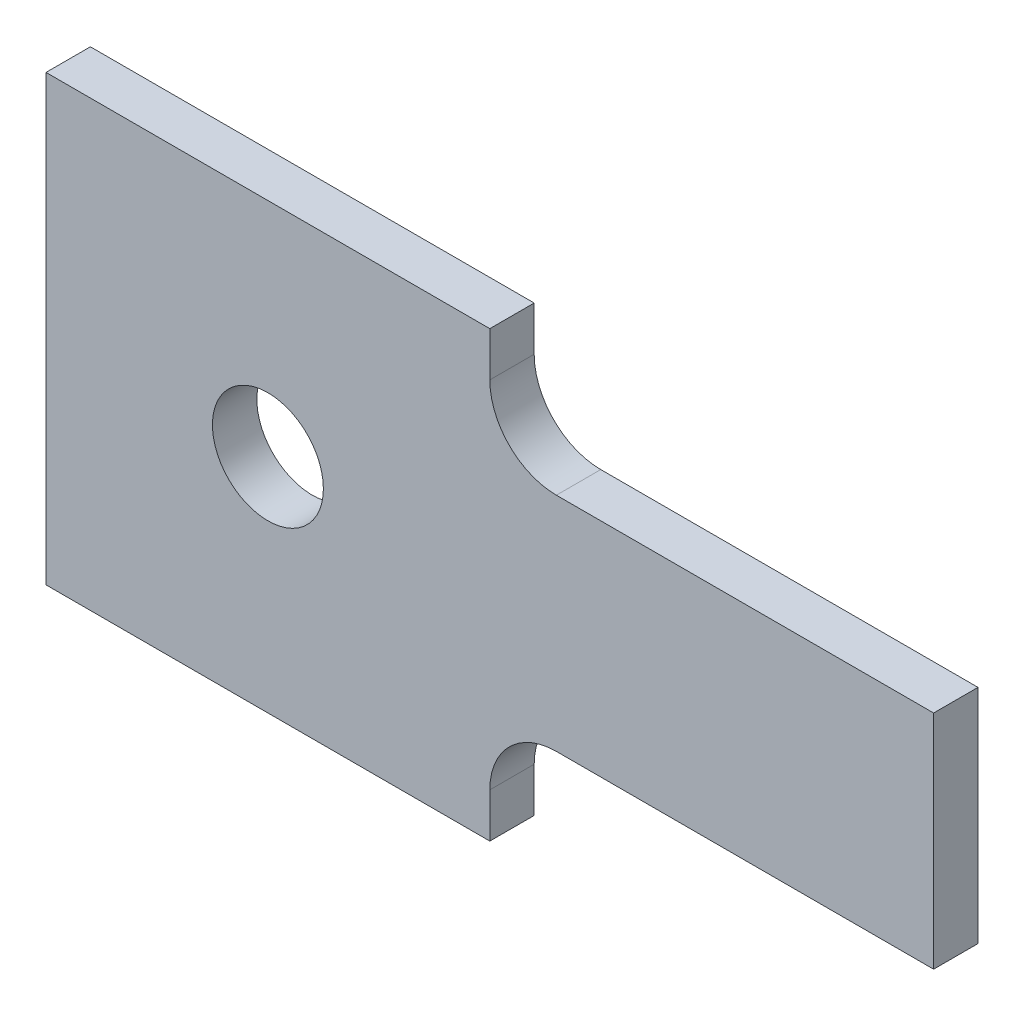
from build123d import *

# Parameters (mm, degrees)
BOSS_EXTRUDE1_DEPTH = 10
SKETCH2_R           = 12.5
CUT_EXTRUDE1_DEPTH  = 11


with BuildPart() as part:
    # Sketch1 → Boss-Extrude1 (new body)
    with BuildSketch(Plane.XY):
        with BuildLine():
            Line((200, -25), (200, 25))
            Line((200, 25), (115, 25))
            ThreePointArc((115, 25), (104.393398282, 29.393398282), (100, 40))
            Line((100, 40), (100, 50))
            Line((100, 50), (0, 50))
            Line((0, 50), (0, -50))
            Line((0, -50), (100, -50))
            Line((100, -50), (100, -40))
            ThreePointArc((100, -40), (104.393398282, -29.393398282), (115, -25))
            Line((115, -25), (200, -25))
        make_face()
    extrude(amount=BOSS_EXTRUDE1_DEPTH)

    # Sketch2 → Cut-Extrude1 (cut, through all)
    with BuildSketch(Plane.XY.offset(10)):
        with Locations((50, 0)):
            Circle(SKETCH2_R)
    extrude(amount=-CUT_EXTRUDE1_DEPTH, mode=Mode.SUBTRACT)


solid = part.part
